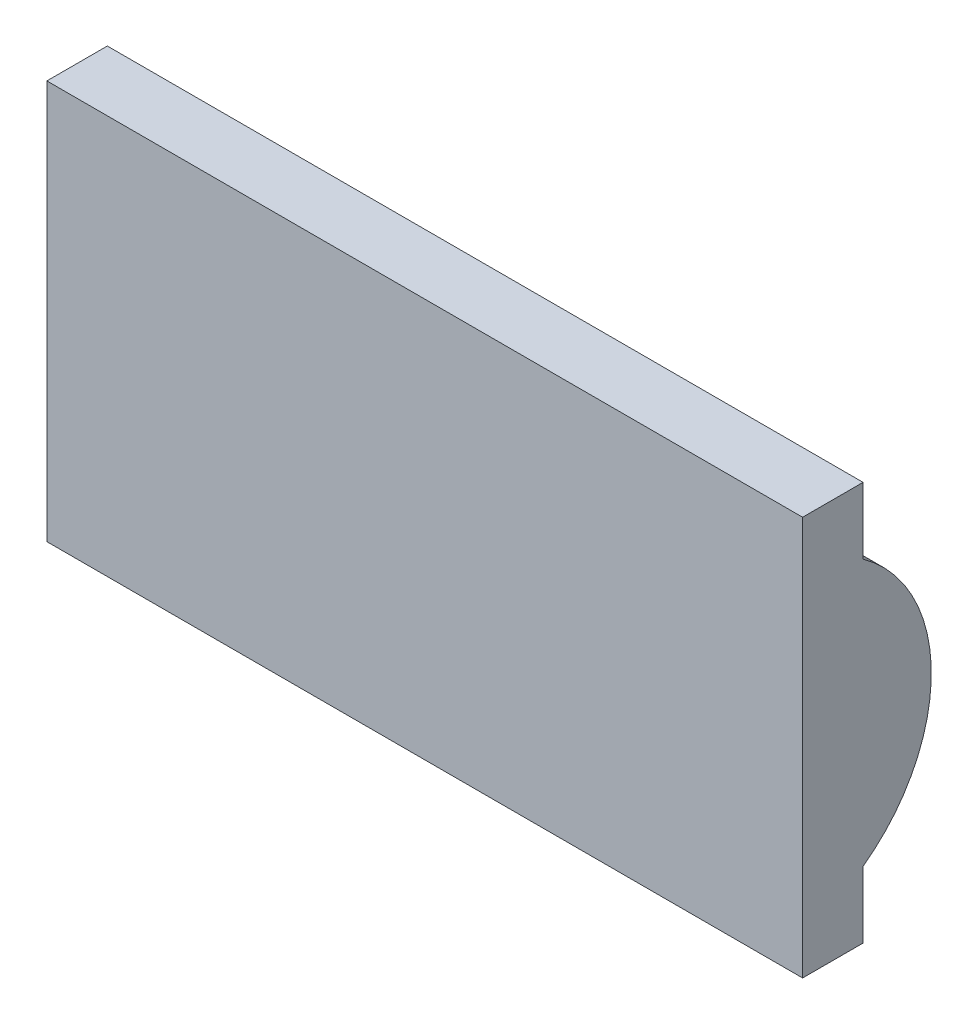
from build123d import *

# Parameters (mm, degrees)
BOSS_EXTRUDE1_DEPTH = 62.5


with BuildPart() as part:
    # Sketch2 → Boss-Extrude1 (new body)
    with BuildSketch(Plane(origin=(0, 0, 0), x_dir=(0, 0, -1), z_dir=(1, 0, 0))):
        with BuildLine():
            Line((0, 25.688444698), (0, -7.311555302))
            Line((0, -7.311555302), (5, -7.311555302))
            Line((5, -7.311555302), (5, -1.811555302))
            ThreePointArc((5, -1.811555302), (10.642520815, 9.188444698), (5, 20.188444698))
            Line((5, 20.188444698), (5, 25.688444698))
            Line((5, 25.688444698), (0, 25.688444698))
        make_face()
    extrude(amount=BOSS_EXTRUDE1_DEPTH)


solid = part.part
